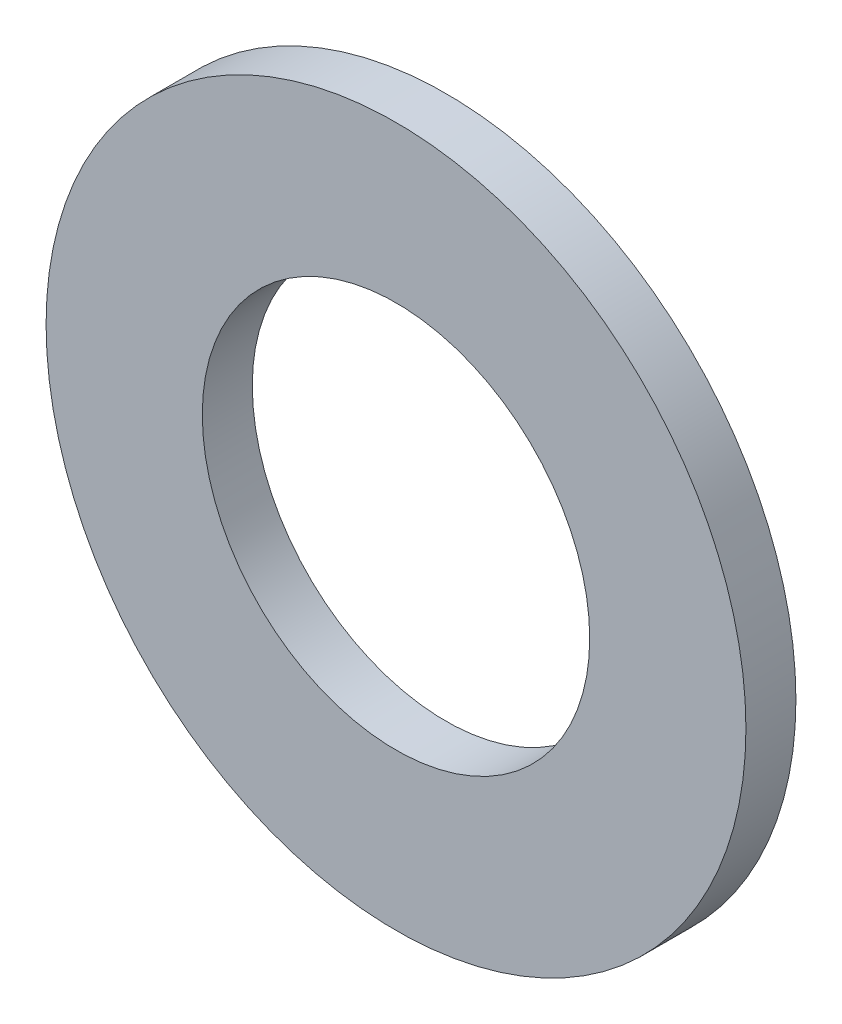
from build123d import *

# Parameters (mm, degrees)
SZKIC1_R                    = 28
SZKIC1_R_2                  = 15.5
DODANIE_WYCI_GNI_CIE1_DEPTH = 4


with BuildPart() as part:
    # Szkic1 → Dodanie-wyciągnięcie1 (new body)
    with BuildSketch(Plane.XY):
        Circle(SZKIC1_R)
        Circle(SZKIC1_R_2, mode=Mode.SUBTRACT)
    extrude(amount=DODANIE_WYCI_GNI_CIE1_DEPTH)


solid = part.part
